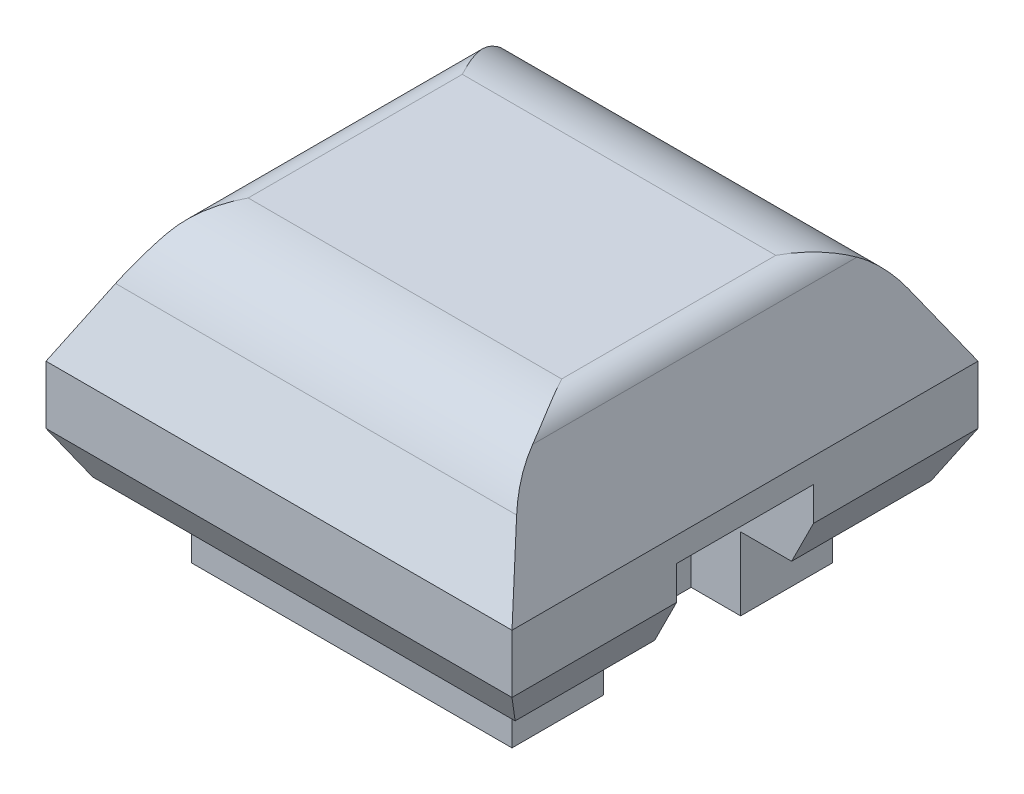
from build123d import *

# Parameters (mm, degrees)
BOSS_EXTRUDE1_DEPTH        = 80
BOSS_EXTRUDE1_DEPTH_BACK   = 80
BOSS_EXTRUDE1_2_DEPTH      = 80
BOSS_EXTRUDE1_2_DEPTH_BACK = 80
CUT_EXTRUDE2_DEPTH         = 81
CUT_EXTRUDE2_DEPTH_BACK    = 81
BOSS_EXTRUDE2_DEPTH        = 20
SKETCH6_W                  = 160
SKETCH6_H                  = 160
CUT_EXTRUDE3_DEPTH         = 25
SKETCH7_W                  = 110
SKETCH7_H                  = 110
BOSS_EXTRUDE3_DEPTH        = 25
SKETCH8_R                  = 2
CUT_EXTRUDE4_DEPTH         = 25
SKETCH9_W                  = 47
SKETCH9_H                  = 51.571101879
CUT_EXTRUDE5_DEPTH         = 42
SKETCH10_R                 = 7.5
BOSS_EXTRUDE4_DEPTH        = 10


with BuildPart() as part:
    # Sketch1 → Boss-Extrude1 (new body, two sides)
    with BuildSketch(Plane.XY) as boss_extrude1_sk:
        with BuildLine():
            Line((-80, 0), (80, 0))
            Line((80, 0), (62.763932023, 34.472135955))
            ThreePointArc((62.763932023, 34.472135955), (59.076971234, 38.506508084), (53.819660113, 40))
            Line((53.819660113, 40), (-53.819660113, 40))
            ThreePointArc((-53.819660113, 40), (-59.076971234, 38.506508084), (-62.763932023, 34.472135955))
            Line((-62.763932023, 34.472135955), (-80, 0))
        make_face()
    extrude(amount=BOSS_EXTRUDE1_DEPTH)
    extrude(boss_extrude1_sk.sketch, amount=-BOSS_EXTRUDE1_DEPTH_BACK)


with BuildPart() as body_2:
    # Sketch1 → Boss-Extrude1 2 (new body, two sides)
    with BuildSketch(Plane.XY) as boss_extrude1_2_sk:
        with BuildLine():
            Line((-62.763932023, -54.472135955), (-80, -20))
            Line((-80, -20), (80, -20))
            Line((80, -20), (62.763932023, -54.472135955))
            ThreePointArc((62.763932023, -54.472135955), (59.076971234, -58.506508084), (53.819660113, -60))
            Line((53.819660113, -60), (-53.819660113, -60))
            ThreePointArc((-53.819660113, -60), (-59.076971234, -58.506508084), (-62.763932023, -54.472135955))
        make_face()
    extrude(amount=BOSS_EXTRUDE1_2_DEPTH)
    extrude(boss_extrude1_2_sk.sketch, amount=-BOSS_EXTRUDE1_2_DEPTH_BACK)


with BuildPart() as cut_extrude2_tool:
    # Sketch2 → Cut-Extrude2 (new body, two sides)
    with BuildSketch(Plane(origin=(0, 0, 0), x_dir=(0, 0, -1), z_dir=(1, 0, 0))) as cut_extrude2_sk:
        with BuildLine():
            Line((67.253579514, 22.306235851), (80, 0))
            Line((80, 0), (80, 40))
            Line((80, 40), (36.764044699, 40))
            ThreePointArc((36.764044699, 40), (54.389885267, 35.256134809), (67.253579514, 22.306235851))
        make_face()
        with BuildLine():
            Line((-67.253579514, 22.306235851), (-80, 0))
            Line((-80, 0), (-80, 40))
            Line((-80, 40), (-36.764044699, 40))
            ThreePointArc((-36.764044699, 40), (-54.389885267, 35.256134809), (-67.253579514, 22.306235851))
        make_face()
        with BuildLine():
            Line((80, -60), (36.764044699, -60))
            ThreePointArc((36.764044699, -60), (54.389885267, -55.256134809), (67.253579514, -42.306235851))
            Line((67.253579514, -42.306235851), (80, -20))
            Line((80, -20), (80, -60))
        make_face()
        with BuildLine():
            Line((-67.253579514, -42.306235851), (-80, -20))
            Line((-80, -20), (-80, -60))
            Line((-80, -60), (-36.764044699, -60))
            ThreePointArc((-36.764044699, -60), (-54.389885267, -55.256134809), (-67.253579514, -42.306235851))
        make_face()
    extrude(amount=CUT_EXTRUDE2_DEPTH)
    extrude(cut_extrude2_sk.sketch, amount=-CUT_EXTRUDE2_DEPTH_BACK)


with BuildPart() as part_1:
    add(part.part)

    # Cut-Extrude2: cut by cut_extrude2_tool
    add(cut_extrude2_tool.part, mode=Mode.SUBTRACT)



with BuildPart() as body_2_1:
    add(body_2.part)

    # Cut-Extrude2: cut by cut_extrude2_tool
    add(cut_extrude2_tool.part, mode=Mode.SUBTRACT)


with BuildPart() as part_2:
    add(part_1.part)

    add(body_2_1.part)  # Boss-Extrude2 merges body 2
    # Sketch3 → Boss-Extrude2 (add)
    with BuildSketch(Plane.XZ):
        Polygon((-71.300354804, -80), (71.300354804, -80), (80, -80), (80, 80), (-80, 80), (-80, -80), align=None)
    extrude(amount=BOSS_EXTRUDE2_DEPTH)

    # Sketch6 → Cut-Extrude3 (cut)
    with BuildSketch(Plane(origin=(0, -60, 0), x_dir=(-1, 0, 0), z_dir=(0, -1, 0))):
        Rectangle(SKETCH6_W, SKETCH6_H)
    extrude(amount=-CUT_EXTRUDE3_DEPTH, mode=Mode.SUBTRACT)

    # Sketch7 → Boss-Extrude3 (add)
    with BuildSketch(Plane(origin=(0, -60, 0), x_dir=(-1, 0, 0), z_dir=(0, -1, 0))):
        Rectangle(SKETCH7_W, SKETCH7_H)
    extrude(amount=-BOSS_EXTRUDE3_DEPTH)

    # Sketch8 → Cut-Extrude4 (cut)
    with BuildSketch(Plane(origin=(0, -60, 0), x_dir=(-1, 0, 0), z_dir=(0, -1, 0))):
        with Locations((-37, -37)):
            Circle(SKETCH8_R)
        with Locations((-37, 37)):
            Circle(SKETCH8_R)
        with Locations((37, 37)):
            Circle(SKETCH8_R)
        with Locations((37, -37)):
            Circle(SKETCH8_R)
    extrude(amount=-CUT_EXTRUDE4_DEPTH, mode=Mode.SUBTRACT)

    # Sketch9 → Cut-Extrude5 (cut)
    with BuildSketch(Plane(origin=(80, 0, 0), x_dir=(0, 0, -1), z_dir=(1, 0, 0))):
        with Locations((0, -34.214449061)):
            Rectangle(SKETCH9_W, SKETCH9_H)
    extrude(amount=-CUT_EXTRUDE5_DEPTH, mode=Mode.SUBTRACT)

    # Sketch10 → Boss-Extrude4 (add)
    with BuildSketch(Plane.XZ.offset(8.428898121)):
        with Locations((49.5, 0)):
            Circle(SKETCH10_R)
    extrude(amount=BOSS_EXTRUDE4_DEPTH)


solid = part_2.part
